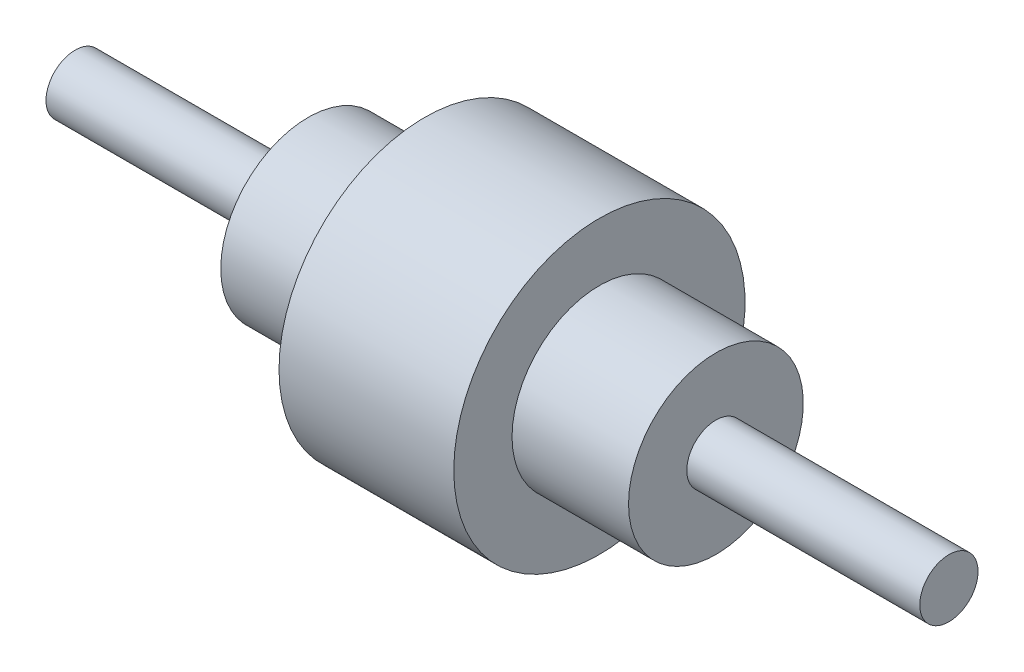
from build123d import *


with BuildPart() as part:
    # Sketch1 → Revolve1 (revolve)
    with BuildSketch(Plane.XY, mode=Mode.PRIVATE) as revolve1_sk:
        Polygon((300, 0), (300, -10), (220, -10), (220, -30), (180, -30), (180, -50), (120, -50), (120, -30), (80, -30), (80, -10), (0, -10), (0, 0), align=None)
    revolve(revolve1_sk.sketch.rotate(Axis((0, 0, 0), (1, 0, 0)), 270), axis=Axis((0, 0, 0), (1, 0, 0)))  # turned: the seam where the file's is


solid = part.part
